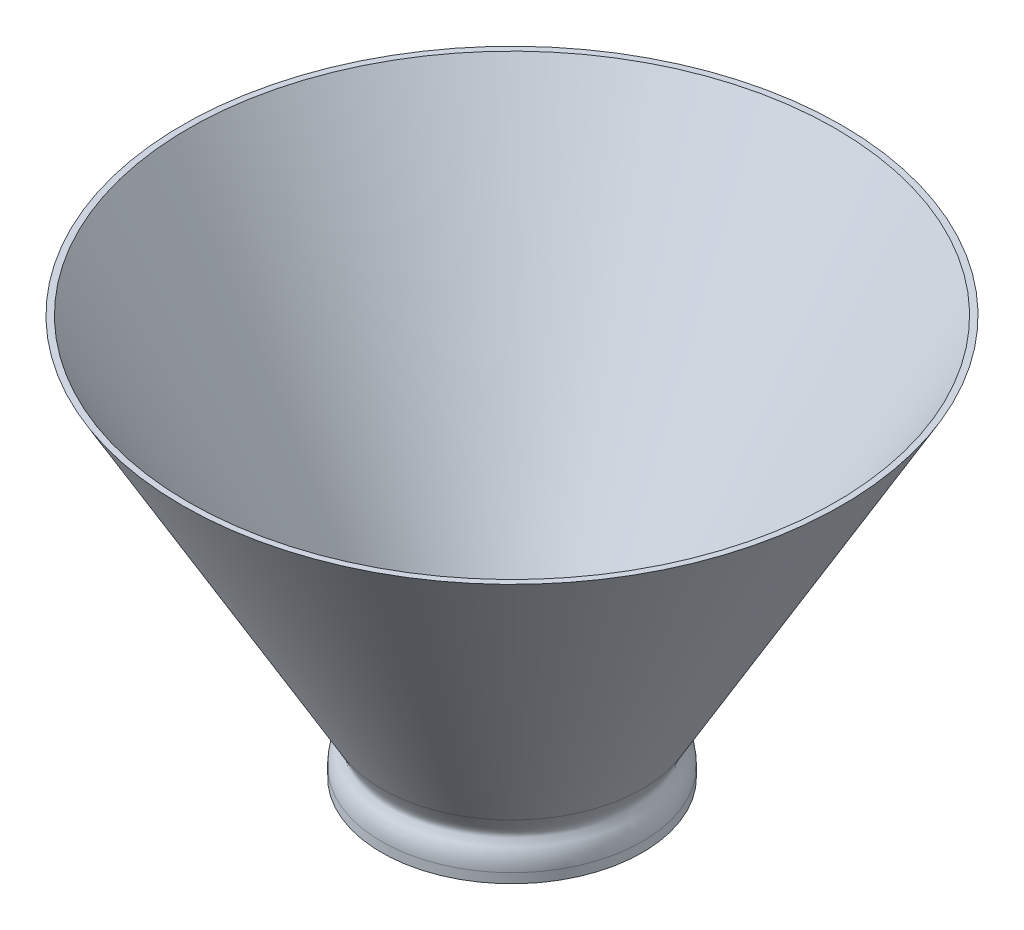
from build123d import *

# Parameters (mm, degrees)
FILLET2_R               = 1.5
SKETCH2_R               = 26.75
CUT_EXTRUDE2_DEPTH      = 101.458946839
CUT_EXTRUDE2_DEPTH_BACK = 1
FILLET3_R               = 10
SKETCH3_R               = 27.802775638
CUT_EXTRUDE3_DEPTH      = 4
SCALE2_SCALE            = 0.41877862


with BuildPart() as part:
    # Sketch1 → Revolve1 (revolve)
    with BuildSketch(Plane.XY):
        with BuildLine():
            Line((23.25, 0), (81.25, 100.458946839))
            Line((81.25, 100.458946839), (82.75, 100.458946839))
            Line((82.75, 100.458946839), (32.75, 13.856406461))
            add(Edge.make_bspline(
                [(32.75, 2.4), (32.75, 6.408142184), (29.482775813, 8.339346474), (30.923478561, 10.692778527), (32.75, 13.856406461)],
                knots=[0, 0, 0, 0, 0.536070096, 1, 1, 1, 1], degree=3))
            Line((32.75, 2.4), (32.75, 0))
            Line((32.75, 0), (31.25, 0))
            Line((31.25, 0), (31.25, 3))
            Line((31.25, 3), (27, 3))
            Line((27, 3), (25, 0))
            Line((25, 0), (23.25, 0))
        make_face()
    revolve(axis=Axis((0, 0, 0), (0, 1, 0)))

    # Fillet2
    fillet2_edges = [part.edges().sort_by_distance(p)[0] for p in [
        (-27, 3, 0),
        (-31.25, 3, 0),
    ]]
    fillet(fillet2_edges, radius=FILLET2_R)

    # Sketch2 → Cut-Extrude2 (cut, two sides)
    with BuildSketch(Plane(origin=(0, 0, 0), x_dir=(1, 0, 0), z_dir=(0, 1, 0))) as cut_extrude2_sk:
        Circle(SKETCH2_R)
    extrude(amount=CUT_EXTRUDE2_DEPTH, mode=Mode.SUBTRACT)
    extrude(cut_extrude2_sk.sketch, amount=-CUT_EXTRUDE2_DEPTH_BACK, mode=Mode.SUBTRACT)

    # Fillet3
    fillet3_edges = [part.edges().sort_by_distance(p)[0] for p in [
        (-26.75, 6.062177826, 0),
    ]]
    fillet(fillet3_edges, radius=FILLET3_R)

    # Sketch3 → Cut-Extrude3 (cut, through all)
    with BuildSketch(Plane.XZ.offset(-3)):
        Circle(SKETCH3_R)
    extrude(amount=CUT_EXTRUDE3_DEPTH, mode=Mode.SUBTRACT)


with BuildPart() as part_1:
    # Scale2: scaled about (4.3607e-05, 55.40616534, 0)
    add(part.part.scale(SCALE2_SCALE).moved(Location((2.5345e-05, 32.203247879, 0))))


solid = part_1.part
